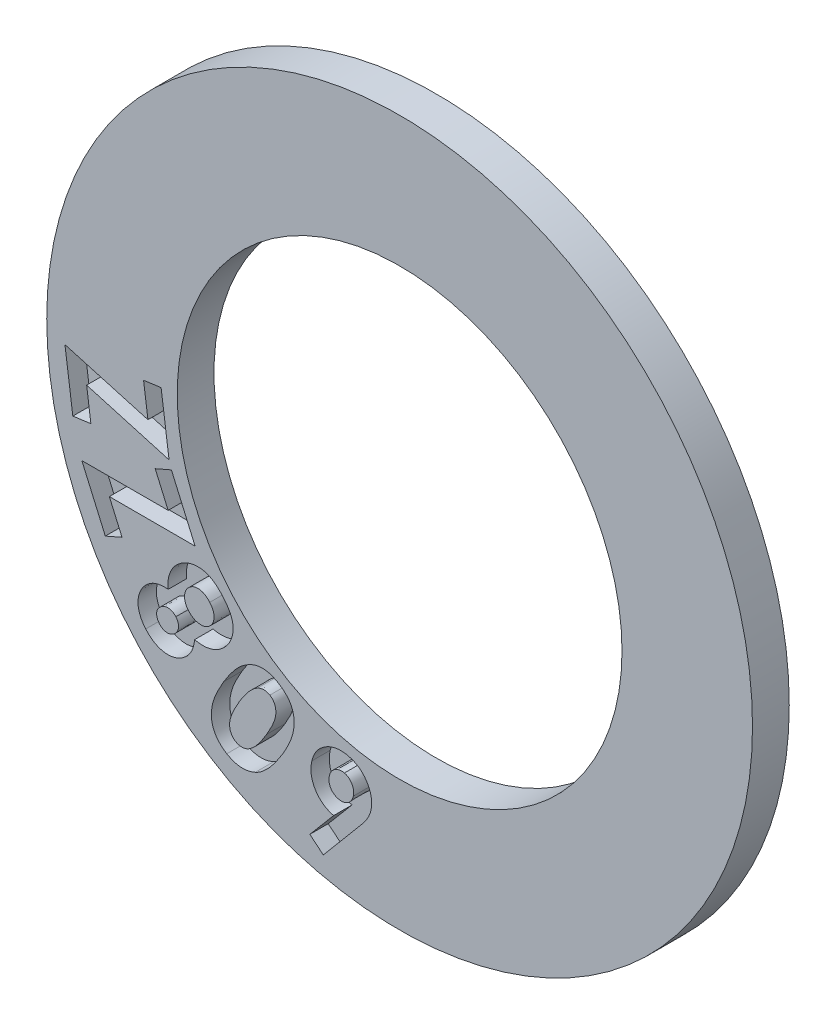
from build123d import *

# Parameters (mm, degrees)
SKETCH1_R           = 9.6
SKETCH1_R_2         = 6.05
BOSS_EXTRUDE1_DEPTH = 1
CUT_EXTRUDE1_DEPTH  = 0.5


with BuildPart() as part:
    # Sketch1 → Boss-Extrude1 (new body)
    with BuildSketch(Plane.XY):
        Circle(SKETCH1_R)
        Circle(SKETCH1_R_2, mode=Mode.SUBTRACT)
    extrude(amount=BOSS_EXTRUDE1_DEPTH)

    # Sketch2 → Cut-Extrude1 (cut)
    with BuildSketch(Plane(origin=(0, 0, 1), x_dir=(-1, 0, 0), z_dir=(0, 0, -1))):
        Polygon((8.890156054, -1.935451646), (9.104252132, -0.357834674), (6.847018848, -0.999481884), (6.965203438, -0.129051987), (6.488667132, -0.064249467), (6.271844521, -1.65761186), (8.514239395, -1.017891134), (8.398753682, -1.868717145), align=None)
        Polygon((8.006176083, -4.320560547), (8.644559969, -2.861239402), (6.297121805, -2.859725528), (6.649059911, -2.054636864), (6.208358864, -1.861621186), (5.563761336, -3.336078487), (7.896306962, -3.334763714), (7.552196812, -4.121778432), align=None)
        with BuildLine():
            add(Edge.make_bspline(
                [(6.292450839, -4.71685014), (6.296231193, -4.682176947), (6.303695055, -4.613718822), (6.299500805, -4.510870124), (6.282570908, -4.410384792), (6.252624945, -4.313037783), (6.210396449, -4.220791991), (6.157710542, -4.134308751), (6.093891309, -4.054693471), (6.043852901, -4.008205609), (6.018613119, -3.984756751)],
                knots=[0, 0, 0, 0, 0.00010452, 0.000206363, 0.000307618, 0.000409487, 0.000510975, 0.000611191, 0.000712636, 0.000815886, 0.000815886, 0.000815886, 0.000815886], degree=3))
            add(Edge.make_bspline(
                [(6.018613119, -3.984756751), (5.989449767, -3.96133002), (5.931785214, -3.915008459), (5.835151695, -3.860987935), (5.732875157, -3.820460949), (5.625912679, -3.793530031), (5.517201798, -3.781285064), (5.409617772, -3.784153092), (5.304570685, -3.801470103), (5.219964587, -3.82967156), (5.153721518, -3.859262004), (5.104035215, -3.886570632), (5.05466803, -3.918917285), (5.004977701, -3.954783044), (4.956144384, -3.995875502), (4.906909349, -4.04052485), (4.857910449, -4.090167931), (4.826505161, -4.125885519), (4.810431036, -4.144166802)],
                knots=[0, 0, 0, 0, 0.000112064, 0.000221584, 0.000330582, 0.000441315, 0.000551489, 0.000657726, 0.000763221, 0.000869699, 0.000924229, 0.000980742, 0.001039564, 0.001101203, 0.001164469, 0.001230913, 0.001300557, 0.001373576, 0.001373576, 0.001373576, 0.001373576], degree=3))
            add(Edge.make_bspline(
                [(4.810431036, -4.144166802), (4.793521732, -4.163962083), (4.760541974, -4.202570626), (4.716083255, -4.261783345), (4.675779028, -4.319263734), (4.641071981, -4.375852092), (4.610055429, -4.430730905), (4.584845547, -4.484850577), (4.56469637, -4.537854511), (4.544080728, -4.606284927), (4.529116978, -4.692371852), (4.525897362, -4.796777852), (4.539194226, -4.901863225), (4.567030692, -5.00642441), (4.609410348, -5.108118487), (4.665566501, -5.204663165), (4.736800609, -5.293833946), (4.793074304, -5.346039497), (4.821752819, -5.372644781)],
                knots=[0, 0, 0, 0, 7.8083e-05, 0.000152293, 0.000222038, 0.000288611, 0.000351368, 0.00041105, 0.000467524, 0.000521348, 0.000625264, 0.00072861, 0.000833586, 0.000941867, 0.00105229, 0.001163113, 0.001275926, 0.001393168, 0.001393168, 0.001393168, 0.001393168], degree=3))
            add(Edge.make_bspline(
                [(4.821752819, -5.372644781), (4.84827292, -5.394154083), (4.900365273, -5.436403929), (4.986017847, -5.487356661), (5.075309221, -5.526581845), (5.168569237, -5.553712707), (5.265540433, -5.569585114), (5.366499219, -5.573878496), (5.471481355, -5.566483537), (5.541707694, -5.552853565), (5.577644402, -5.545878741)],
                knots=[0, 0, 0, 0, 0.000102331, 0.000201005, 0.000297918, 0.000394202, 0.000491587, 0.000592, 0.000696715, 0.00080646, 0.00080646, 0.00080646, 0.00080646], degree=3))
            add(Edge.make_bspline(
                [(5.577644402, -5.545878741), (5.580484821, -5.57331704), (5.586042257, -5.627001569), (5.602578712, -5.704928), (5.625289884, -5.778455797), (5.653676969, -5.848097739), (5.688567781, -5.913356571), (5.729814822, -5.974219876), (5.777994102, -6.030122423), (5.814206137, -6.063566), (5.832440685, -6.080406493)],
                knots=[0, 0, 0, 0, 8.2709e-05, 0.000161826, 0.000238509, 0.000313324, 0.00038709, 0.000460101, 0.000533475, 0.000607898, 0.000607898, 0.000607898, 0.000607898], degree=3))
            add(Edge.make_bspline(
                [(5.832440685, -6.080406493), (5.858665818, -6.101709414), (5.910224428, -6.143590956), (5.996641344, -6.192165189), (6.087035961, -6.22931833), (6.181811268, -6.252399652), (6.278094963, -6.263746053), (6.374950486, -6.260788022), (6.471110637, -6.24375008), (6.565922949, -6.212761042), (6.658253372, -6.1691234), (6.746534075, -6.111932026), (6.830596994, -6.042033888), (6.880739865, -5.987160124), (6.906414341, -5.959063305)],
                knots=[0, 0, 0, 0, 0.000101201, 0.000198961, 0.000296133, 0.000393575, 0.000490639, 0.000586162, 0.000683191, 0.000782611, 0.00088455, 0.000988684, 0.0010974, 0.001211476, 0.001211476, 0.001211476, 0.001211476], degree=3))
            add(Edge.make_bspline(
                [(6.906414341, -5.959063305), (6.930091547, -5.92995382), (6.976201186, -5.873265211), (7.03165128, -5.78095692), (7.073902846, -5.686403705), (7.102885757, -5.589810237), (7.117484265, -5.491987108), (7.118855172, -5.394271522), (7.105995939, -5.296932667), (7.079327362, -5.20165659), (7.040880325, -5.110227547), (6.990961989, -5.025267159), (6.930708481, -4.947258172), (6.88254917, -4.902640549), (6.858279071, -4.8801553)],
                knots=[0, 0, 0, 0, 0.000112456, 0.000218999, 0.000321926, 0.000422467, 0.000520548, 0.000617704, 0.00071471, 0.000814043, 0.000913671, 0.001011403, 0.001108962, 0.001208076, 0.001208076, 0.001208076, 0.001208076], degree=3))
            add(Edge.make_bspline(
                [(6.858279071, -4.8801553), (6.840406243, -4.865452673), (6.805097485, -4.836406821), (6.747192554, -4.800652805), (6.68754033, -4.770561757), (6.624039757, -4.746759924), (6.554057879, -4.730157101), (6.475508354, -4.719451316), (6.387142401, -4.715232318), (6.325105968, -4.716292221), (6.292450839, -4.71685014)],
                knots=[0, 0, 0, 0, 6.9359e-05, 0.000137023, 0.00020363, 0.000269576, 0.000339948, 0.000418941, 0.000507087, 0.000605053, 0.000605053, 0.000605053, 0.000605053], degree=3))
        make_face()
        with BuildLine():
            add(Edge.make_bspline(
                [(6.528704439, -5.654884461), (6.514953656, -5.669113344), (6.488277314, -5.696717194), (6.441148505, -5.728765106), (6.38896261, -5.748062241), (6.334115668, -5.757314463), (6.277931544, -5.755603918), (6.223128002, -5.741699743), (6.170374192, -5.716716442), (6.139515683, -5.692163431), (6.123537132, -5.67944987)],
                knots=[0, 0, 0, 0, 5.9272e-05, 0.000114986, 0.000169255, 0.000224917, 0.000280951, 0.000336562, 0.000393451, 0.000454541, 0.000454541, 0.000454541, 0.000454541], degree=3))
            add(Edge.make_bspline(
                [(6.123537132, -5.67944987), (6.108638416, -5.665300977), (6.079666339, -5.637787007), (6.046636074, -5.588359409), (6.024823834, -5.534086591), (6.015305285, -5.476367407), (6.015003434, -5.418131181), (6.027987455, -5.361935246), (6.051225953, -5.308569628), (6.075255605, -5.277765574), (6.087517856, -5.262046367)],
                knots=[0, 0, 0, 0, 6.1491e-05, 0.000119575, 0.000176782, 0.000235636, 0.000294106, 0.00035031, 0.000407505, 0.000467105, 0.000467105, 0.000467105, 0.000467105], degree=3))
            add(Edge.make_bspline(
                [(6.087517856, -5.262046367), (6.101510342, -5.247338222), (6.128829254, -5.218622056), (6.177937638, -5.186368361), (6.231546554, -5.165790901), (6.288266006, -5.157064195), (6.345984758, -5.159584898), (6.402728349, -5.174663066), (6.457698751, -5.201012922), (6.490243559, -5.226862284), (6.507015182, -5.24018348)],
                knots=[0, 0, 0, 0, 6.0751e-05, 0.00011861, 0.000174546, 0.00023179, 0.000289583, 0.000346582, 0.000406854, 0.000470942, 0.000470942, 0.000470942, 0.000470942], degree=3))
            add(Edge.make_bspline(
                [(6.507015182, -5.24018348), (6.521703742, -5.25418743), (6.550265559, -5.281418026), (6.582549218, -5.329906797), (6.60285203, -5.38265022), (6.612371975, -5.438223329), (6.609211442, -5.495220895), (6.594682857, -5.55145763), (6.567502624, -5.605709232), (6.541960422, -5.638083005), (6.528704439, -5.654884461)],
                knots=[0, 0, 0, 0, 6.0751e-05, 0.00011813, 0.000173032, 0.000229223, 0.000285977, 0.000342975, 0.000402375, 0.000466462, 0.000466462, 0.000466462, 0.000466462], degree=3))
        make_face(mode=Mode.SUBTRACT)
        with BuildLine():
            add(Edge.make_bspline(
                [(5.740044344, -4.948573334), (5.720070805, -4.969954484), (5.681227048, -5.01153571), (5.611768457, -5.059093508), (5.536951685, -5.09230451), (5.470711432, -5.106783356), (5.417253435, -5.110951474), (5.37824682, -5.111242186), (5.340744562, -5.106725334), (5.304771761, -5.099591733), (5.270426688, -5.087597677), (5.237734159, -5.072230809), (5.206484037, -5.052906165), (5.187396206, -5.03747111), (5.177673068, -5.029608658)],
                knots=[0, 0, 0, 0, 8.7562e-05, 0.000170286, 0.00025052, 0.000331822, 0.00037219, 0.000411318, 0.0004486, 0.000485324, 0.000521119, 0.000557428, 0.000593531, 0.000631016, 0.000631016, 0.000631016, 0.000631016], degree=3))
            add(Edge.make_bspline(
                [(5.177673068, -5.029608658), (5.167946182, -5.020854263), (5.148705975, -5.003537687), (5.123507828, -4.974562572), (5.102428651, -4.94350241), (5.083766112, -4.911357201), (5.069815746, -4.876784002), (5.059043936, -4.840702968), (5.051909497, -4.802982521), (5.048367479, -4.764058805), (5.048153995, -4.724514282), (5.052776713, -4.685142855), (5.060872626, -4.646134239), (5.073567926, -4.607634822), (5.090685024, -4.569775206), (5.11136589, -4.532373576), (5.136347733, -4.495616779), (5.155441251, -4.472297757), (5.16526343, -4.460301873)],
                knots=[0, 0, 0, 0, 3.9235e-05, 7.7609e-05, 0.000114824, 0.000151735, 0.000188885, 0.000226363, 0.000264557, 0.000303835, 0.000343487, 0.000382955, 0.000422532, 0.000462828, 0.000504291, 0.000547012, 0.000590901, 0.000637398, 0.000637398, 0.000637398, 0.000637398], degree=3))
            add(Edge.make_bspline(
                [(5.16526343, -4.460301873), (5.186008103, -4.4379681), (5.225880297, -4.395041585), (5.294998532, -4.345183994), (5.367568788, -4.310934135), (5.43065478, -4.296395612), (5.480923804, -4.292160189), (5.517871217, -4.294148538), (5.554170098, -4.298486238), (5.589266671, -4.308241531), (5.623798272, -4.320627974), (5.656661719, -4.338129604), (5.689259332, -4.358599804), (5.709373765, -4.375148464), (5.719711028, -4.383653197)],
                knots=[0, 0, 0, 0, 9.1269e-05, 0.000175423, 0.000253908, 0.000330494, 0.000368219, 0.000404912, 0.000441314, 0.000477642, 0.000513936, 0.00055115, 0.000589093, 0.00062921, 0.00062921, 0.00062921, 0.00062921], degree=3))
            add(Edge.make_bspline(
                [(5.719711028, -4.383653197), (5.729681879, -4.39251888), (5.749334636, -4.409993329), (5.774448754, -4.439862631), (5.796355416, -4.471011779), (5.814827057, -4.503747205), (5.82894589, -4.538405481), (5.839763209, -4.574674413), (5.846844683, -4.612744006), (5.850773242, -4.652225956), (5.849925937, -4.692065526), (5.846568376, -4.731565139), (5.837700947, -4.769884361), (5.82653983, -4.80781393), (5.810145714, -4.844353696), (5.790599185, -4.880235962), (5.767501488, -4.91543114), (5.74930062, -4.93740053), (5.740044344, -4.948573334)],
                knots=[0, 0, 0, 0, 3.998e-05, 7.8802e-05, 0.000116726, 0.000154133, 0.000191283, 0.000228761, 0.000267484, 0.000307292, 0.000347549, 0.000386884, 0.000425965, 0.000465319, 0.00050532, 0.000545813, 0.000587848, 0.000631348, 0.000631348, 0.000631348, 0.000631348], degree=3))
        make_face(mode=Mode.SUBTRACT)
        with BuildLine():
            add(Edge.make_bspline(
                [(4.700728427, -7.795616742), (4.720638572, -7.783132272), (4.759771347, -7.758594433), (4.814470153, -7.717412313), (4.864783206, -7.674033873), (4.911525287, -7.628615178), (4.953089061, -7.580121214), (4.990332788, -7.529021594), (5.023192318, -7.475643947), (5.052307077, -7.420027909), (5.075721636, -7.361605919), (5.09438204, -7.300769393), (5.108837783, -7.237649153), (5.117037831, -7.171861113), (5.122292406, -7.103935486), (5.120061159, -7.03350088), (5.115322827, -6.960556113), (5.104257609, -6.884763911), (5.087761363, -6.805773677), (5.064315426, -6.722859126), (5.033804865, -6.635967285), (4.997996979, -6.544058453), (4.953618583, -6.448781817), (4.904050752, -6.348644833), (4.847445386, -6.244464118), (4.80596073, -6.174526152), (4.784625576, -6.138557739)],
                knots=[0, 0, 0, 0, 7.0476e-05, 0.000138518, 0.000205151, 0.000269684, 0.000333842, 0.000396505, 0.000459191, 0.000521735, 0.000584599, 0.000647697, 0.000712498, 0.000778565, 0.000846426, 0.000916644, 0.000989736, 0.001065645, 0.001146197, 0.001231675, 0.001323919, 0.001422396, 0.001527454, 0.001639098, 0.001757579, 0.001883033, 0.001883033, 0.001883033, 0.001883033], degree=3))
            add(Edge.make_bspline(
                [(4.784625576, -6.138557739), (4.762727322, -6.102465829), (4.720119225, -6.032240707), (4.652841848, -5.933253224), (4.587662436, -5.841265745), (4.522388818, -5.7580152), (4.458981279, -5.681672652), (4.394778634, -5.61469299), (4.332245522, -5.554650767), (4.269546607, -5.502929045), (4.207279173, -5.45808791), (4.145461656, -5.419001916), (4.084621454, -5.384417752), (4.02329979, -5.356953344), (3.963161648, -5.332807942), (3.902752166, -5.315711695), (3.842918751, -5.303161926), (3.783299336, -5.296359015), (3.723512487, -5.295196556), (3.66339586, -5.298833071), (3.602630182, -5.307685857), (3.541575369, -5.322483631), (3.480026857, -5.342273676), (3.418196877, -5.367631761), (3.355317386, -5.397304502), (3.31447702, -5.421146208), (3.293602704, -5.433332174)],
                knots=[0, 0, 0, 0, 0.000126625, 0.000246378, 0.000358967, 0.000464768, 0.000563682, 0.000656536, 0.000742955, 0.000823618, 0.000900148, 0.000972993, 0.001042973, 0.001109858, 0.001174418, 0.001237202, 0.00129792, 0.001357664, 0.001416921, 0.001477096, 0.001538158, 0.001600882, 0.001665348, 0.001731921, 0.001801248, 0.001873728, 0.001873728, 0.001873728, 0.001873728], degree=3))
            add(Edge.make_bspline(
                [(3.293602704, -5.433332174), (3.27314021, -5.446130931), (3.233042204, -5.471211191), (3.176956879, -5.512848598), (3.125200633, -5.556071252), (3.078120873, -5.601703467), (3.036034509, -5.649641441), (2.998676876, -5.699670076), (2.966410245, -5.752013109), (2.938189331, -5.806269788), (2.914892485, -5.86296653), (2.8964833, -5.922169481), (2.882544486, -5.983605113), (2.873667331, -6.047736577), (2.869269786, -6.114019568), (2.86899656, -6.182799587), (2.874568071, -6.253723252), (2.88362701, -6.327664531), (2.898922501, -6.404987596), (2.921299366, -6.48625663), (2.949718077, -6.57216816), (2.985898136, -6.662414117), (3.02857333, -6.757326057), (3.078491547, -6.856553019), (3.134315936, -6.960696163), (3.17581114, -7.030463309), (3.197190336, -7.066408801)],
                knots=[0, 0, 0, 0, 7.2381e-05, 0.000141838, 0.000209356, 0.000274556, 0.000338319, 0.000400536, 0.000461635, 0.000522589, 0.000583819, 0.000645258, 0.000708385, 0.000772596, 0.000839272, 0.000907552, 0.000978734, 0.001052548, 0.001130937, 0.00121494, 0.001305281, 0.001402264, 0.001506484, 0.001617388, 0.001735429, 0.001860882, 0.001860882, 0.001860882, 0.001860882], degree=3))
            add(Edge.make_bspline(
                [(3.197190336, -7.066408801), (3.227521409, -7.115790646), (3.286145503, -7.211236197), (3.379508936, -7.343863115), (3.470734731, -7.463449574), (3.561917821, -7.568707565), (3.653489188, -7.658961496), (3.743760065, -7.736187022), (3.833981775, -7.799437674), (3.896876706, -7.831198338), (3.927187721, -7.846504786)],
                knots=[0, 0, 0, 0, 0.000173819, 0.000335958, 0.000486326, 0.000624914, 0.000753353, 0.000871664, 0.000981059, 0.001082823, 0.001082823, 0.001082823, 0.001082823], degree=3))
            add(Edge.make_bspline(
                [(3.927187721, -7.846504786), (3.959833229, -7.859853273), (4.023763131, -7.885993697), (4.122705669, -7.911422322), (4.220859884, -7.924245793), (4.318567478, -7.924223873), (4.41578037, -7.911548326), (4.512304869, -7.885748904), (4.608378293, -7.847490073), (4.66942776, -7.813198415), (4.700728427, -7.795616742)],
                knots=[0, 0, 0, 0, 0.000105711, 0.000207015, 0.000305462, 0.000401957, 0.000499306, 0.000598708, 0.00070098, 0.000808587, 0.000808587, 0.000808587, 0.000808587], degree=3))
        make_face()
        with BuildLine():
            add(Edge.make_bspline(
                [(4.466967208, -7.38342652), (4.448890208, -7.393193098), (4.413183596, -7.41248454), (4.354772228, -7.42928388), (4.294401622, -7.43614614), (4.242906327, -7.432170968), (4.200914994, -7.423650291), (4.168345129, -7.412987653), (4.135148967, -7.39833475), (4.101373041, -7.379895981), (4.067312802, -7.357305604), (4.032006124, -7.331819656), (3.996838211, -7.301367811), (3.960091155, -7.26769048), (3.922421853, -7.228999048), (3.883779817, -7.184542264), (3.843816188, -7.134075909), (3.800707034, -7.079226192), (3.758352063, -7.016807493), (3.712629697, -6.950106555), (3.665769298, -6.877211239), (3.634851609, -6.82624606), (3.618869002, -6.799900092)],
                knots=[0, 0, 0, 0, 6.1491e-05, 0.00012146, 0.000180996, 0.000242938, 0.000275481, 0.000309377, 0.000345515, 0.00038421, 0.000424662, 0.000468061, 0.000514742, 0.00056411, 0.000617578, 0.000676636, 0.000740733, 0.000810697, 0.000885842, 0.000966934, 0.001053318, 0.001145761, 0.001145761, 0.001145761, 0.001145761], degree=3))
            add(Edge.make_bspline(
                [(3.618869002, -6.799900092), (3.598573185, -6.765708357), (3.559566788, -6.699995487), (3.507591618, -6.602993389), (3.46363256, -6.512424232), (3.427957509, -6.42800269), (3.399874383, -6.350205195), (3.380355568, -6.278333427), (3.3679065, -6.212858126), (3.364985536, -6.152819332), (3.368657975, -6.098327532), (3.375734578, -6.047982592), (3.389486908, -6.00192671), (3.407247096, -5.959376387), (3.430784175, -5.920998119), (3.458643459, -5.885923435), (3.492280681, -5.855480725), (3.517703807, -5.838826579), (3.530539313, -5.830418313)],
                knots=[0, 0, 0, 0, 0.000119273, 0.000229231, 0.000330042, 0.000421183, 0.000504077, 0.000577955, 0.000644429, 0.000703604, 0.000757688, 0.00080814, 0.000855747, 0.000901479, 0.000946079, 0.00099036, 0.001035461, 0.00108145, 0.00108145, 0.00108145, 0.00108145], degree=3))
            add(Edge.make_bspline(
                [(3.530539313, -5.830418313), (3.543548509, -5.823214546), (3.568936617, -5.809156027), (3.609574553, -5.794761023), (3.650929524, -5.78626144), (3.693389203, -5.783895463), (3.736837693, -5.787611347), (3.781277725, -5.797199757), (3.826368534, -5.813319021), (3.855617051, -5.827961566), (3.870647544, -5.835486209)],
                knots=[0, 0, 0, 0, 4.455e-05, 8.6941e-05, 0.000128745, 0.00017083, 0.000214048, 0.000259187, 0.000306859, 0.000357255, 0.000357255, 0.000357255, 0.000357255], degree=3))
            add(Edge.make_bspline(
                [(3.870647544, -5.835486209), (3.889815553, -5.846599485), (3.929966672, -5.869878402), (3.987107768, -5.915746086), (4.045971796, -5.970328754), (4.106245405, -6.034814404), (4.167607751, -6.109454037), (4.229946795, -6.194302238), (4.294110642, -6.288510748), (4.335451915, -6.355680363), (4.3568648, -6.390471147)],
                knots=[0, 0, 0, 0, 6.6387e-05, 0.000139061, 0.000219157, 0.000307153, 0.000403616, 0.00050887, 0.000622917, 0.00074546, 0.00074546, 0.00074546, 0.00074546], degree=3))
            add(Edge.make_bspline(
                [(4.3568648, -6.390471147), (4.377758813, -6.426067567), (4.41787646, -6.494414639), (4.472748121, -6.594397123), (4.51870216, -6.688059858), (4.556327766, -6.775135046), (4.586489077, -6.855404608), (4.607435764, -6.929333618), (4.620966111, -6.99659022), (4.625675287, -7.05784245), (4.623554444, -7.113625699), (4.615867183, -7.164726941), (4.604216218, -7.211910835), (4.586282903, -7.254523246), (4.564338567, -7.293381221), (4.536852037, -7.327896894), (4.504611824, -7.358745865), (4.479610929, -7.375137013), (4.466967208, -7.38342652)],
                knots=[0, 0, 0, 0, 0.000123824, 0.000237749, 0.000342065, 0.000436676, 0.000522244, 0.000599096, 0.000666971, 0.000727703, 0.000782939, 0.000834066, 0.000882533, 0.000928311, 0.000972331, 0.001015992, 0.001060241, 0.001105516, 0.001105516, 0.001105516, 0.001105516], degree=3))
        make_face(mode=Mode.SUBTRACT)
        with BuildLine():
            Line((2.075975898, -8.867229502), (2.442037742, -8.564737894))
            Line((2.442037742, -8.564737894), (1.794478505, -7.798544074))
            add(Edge.make_bspline(
                [(1.794478505, -7.798544074), (1.820964617, -7.79179497), (1.873067153, -7.778518373), (1.947212391, -7.748786528), (2.017197131, -7.7137812), (2.08270224, -7.671966929), (2.142674771, -7.62271753), (2.19866903, -7.56776453), (2.248980162, -7.505552249), (2.294830283, -7.438128539), (2.334168318, -7.366324115), (2.365758356, -7.291692022), (2.389809342, -7.215368145), (2.405504367, -7.137094957), (2.413214049, -7.056855229), (2.412408568, -6.974657237), (2.404990885, -6.890498257), (2.393160628, -6.834639339), (2.387161775, -6.806314557)],
                knots=[0, 0, 0, 0, 8.1918e-05, 0.000161146, 0.000239065, 0.000316443, 0.000393711, 0.000471481, 0.000551402, 0.000633315, 0.000715815, 0.000796588, 0.000876073, 0.000955472, 0.001035647, 0.00111743, 0.001201796, 0.001288584, 0.001288584, 0.001288584, 0.001288584], degree=3))
            add(Edge.make_bspline(
                [(2.387161775, -6.806314557), (2.380192006, -6.77914442), (2.366473564, -6.725666041), (2.337273296, -6.64899094), (2.301124513, -6.577312958), (2.258432192, -6.510669761), (2.209874211, -6.448476891), (2.154059485, -6.39152331), (2.091415237, -6.339736705), (2.023339261, -6.292889797), (1.951339053, -6.252916884), (1.877201322, -6.220071063), (1.801586439, -6.195074715), (1.724551245, -6.178663361), (1.646197361, -6.169540412), (1.5665705, -6.169113773), (1.485435115, -6.175734798), (1.431760629, -6.186797037), (1.404618601, -6.192390972)],
                knots=[0, 0, 0, 0, 8.4099e-05, 0.00016553, 0.000245569, 0.000324527, 0.000402598, 0.000481875, 0.000563244, 0.000646077, 0.000729445, 0.00080993, 0.000889016, 0.000967903, 0.00104583, 0.001125235, 0.001206439, 0.00128951, 0.00128951, 0.00128951, 0.00128951], degree=3))
            add(Edge.make_bspline(
                [(1.404618601, -6.192390972), (1.376563169, -6.199545719), (1.321334913, -6.213630128), (1.242449318, -6.24407306), (1.168944519, -6.28119918), (1.100273379, -6.324280596), (1.037967382, -6.375338619), (0.980587411, -6.432265549), (0.928156195, -6.495785396), (0.882718775, -6.565757455), (0.842689307, -6.63876944), (0.810778608, -6.713525595), (0.785926014, -6.78855468), (0.768880184, -6.864270238), (0.760180961, -6.940639218), (0.759052812, -7.01745304), (0.76503761, -7.094798126), (0.775497423, -7.145800118), (0.780772208, -7.171519941)],
                knots=[0, 0, 0, 0, 8.6801e-05, 0.000170872, 0.000253031, 0.000333568, 0.000413538, 0.000494157, 0.000575745, 0.000660099, 0.000744078, 0.000825251, 0.000903588, 0.000980899, 0.001057647, 0.001133735, 0.001211097, 0.001289798, 0.001289798, 0.001289798, 0.001289798], degree=3))
            add(Edge.make_bspline(
                [(0.780772208, -7.171519941), (0.785695075, -7.191266775), (0.795566926, -7.230865209), (0.816684362, -7.288885259), (0.841553823, -7.346284436), (0.866665251, -7.393732867), (0.890667918, -7.432879936), (0.911992965, -7.465983752), (0.937591986, -7.502234227), (0.966962321, -7.54172392), (0.999782204, -7.584942106), (1.036636897, -7.631227095), (1.077395048, -7.680940574), (1.106233971, -7.71491697), (1.121207521, -7.732557964)],
                knots=[0, 0, 0, 0, 6.1016e-05, 0.000122356, 0.000184954, 0.000248591, 0.000283188, 0.000322699, 0.000366703, 0.000416289, 0.00047034, 0.000529496, 0.000593774, 0.00066319, 0.00066319, 0.00066319, 0.00066319], degree=3))
            Line((1.121207521, -7.732557964), (2.075975898, -8.867229502))
        make_face()
        with BuildLine():
            add(Edge.make_bspline(
                [(1.659476858, -7.344258013), (1.637398016, -7.348178216), (1.594123199, -7.355861864), (1.528587008, -7.350615517), (1.465854129, -7.332444684), (1.40766774, -7.300415508), (1.355426899, -7.257773565), (1.312424441, -7.204802184), (1.278869212, -7.143153769), (1.266287616, -7.097452272), (1.259823616, -7.073972381)],
                knots=[0, 0, 0, 0, 6.7042e-05, 0.000131403, 0.000195186, 0.000261666, 0.000329262, 0.000396241, 0.000465194, 0.000538051, 0.000538051, 0.000538051, 0.000538051], degree=3))
            add(Edge.make_bspline(
                [(1.259823616, -7.073972381), (1.255616103, -7.049928845), (1.247421663, -7.003102287), (1.250195961, -6.932155229), (1.267606693, -6.864588265), (1.297889604, -6.802066786), (1.336866966, -6.746324165), (1.384713086, -6.7010004), (1.43999171, -6.667469749), (1.480865077, -6.655442176), (1.50143053, -6.649390497)],
                knots=[0, 0, 0, 0, 7.3077e-05, 0.000142322, 0.000211136, 0.000280915, 0.000349695, 0.000414069, 0.000477363, 0.00054146, 0.00054146, 0.00054146, 0.00054146], degree=3))
            add(Edge.make_bspline(
                [(1.50143053, -6.649390497), (1.523510207, -6.645451061), (1.567025374, -6.637687126), (1.633434453, -6.643375638), (1.697704716, -6.661954015), (1.758536441, -6.69327309), (1.813280003, -6.735883842), (1.85784641, -6.789675388), (1.892551949, -6.852425754), (1.905529723, -6.899127896), (1.912191673, -6.923101756)],
                knots=[0, 0, 0, 0, 6.7042e-05, 0.000132128, 0.000197801, 0.000266703, 0.000336159, 0.000404418, 0.000474982, 0.000549412, 0.000549412, 0.000549412, 0.000549412], degree=3))
            add(Edge.make_bspline(
                [(1.912191673, -6.923101756), (1.916661267, -6.947069107), (1.925347059, -6.993645032), (1.921650589, -7.063815135), (1.906139154, -7.130626411), (1.87604538, -7.192032803), (1.836005101, -7.246841219), (1.785370097, -7.29107821), (1.726297756, -7.325370563), (1.682203464, -7.33783416), (1.659476858, -7.344258013)],
                knots=[0, 0, 0, 0, 7.2913e-05, 0.000141693, 0.00020908, 0.000277369, 0.000345403, 0.000411366, 0.000477754, 0.000548363, 0.000548363, 0.000548363, 0.000548363], degree=3))
        make_face(mode=Mode.SUBTRACT)
    extrude(amount=CUT_EXTRUDE1_DEPTH, mode=Mode.SUBTRACT)


solid = part.part
